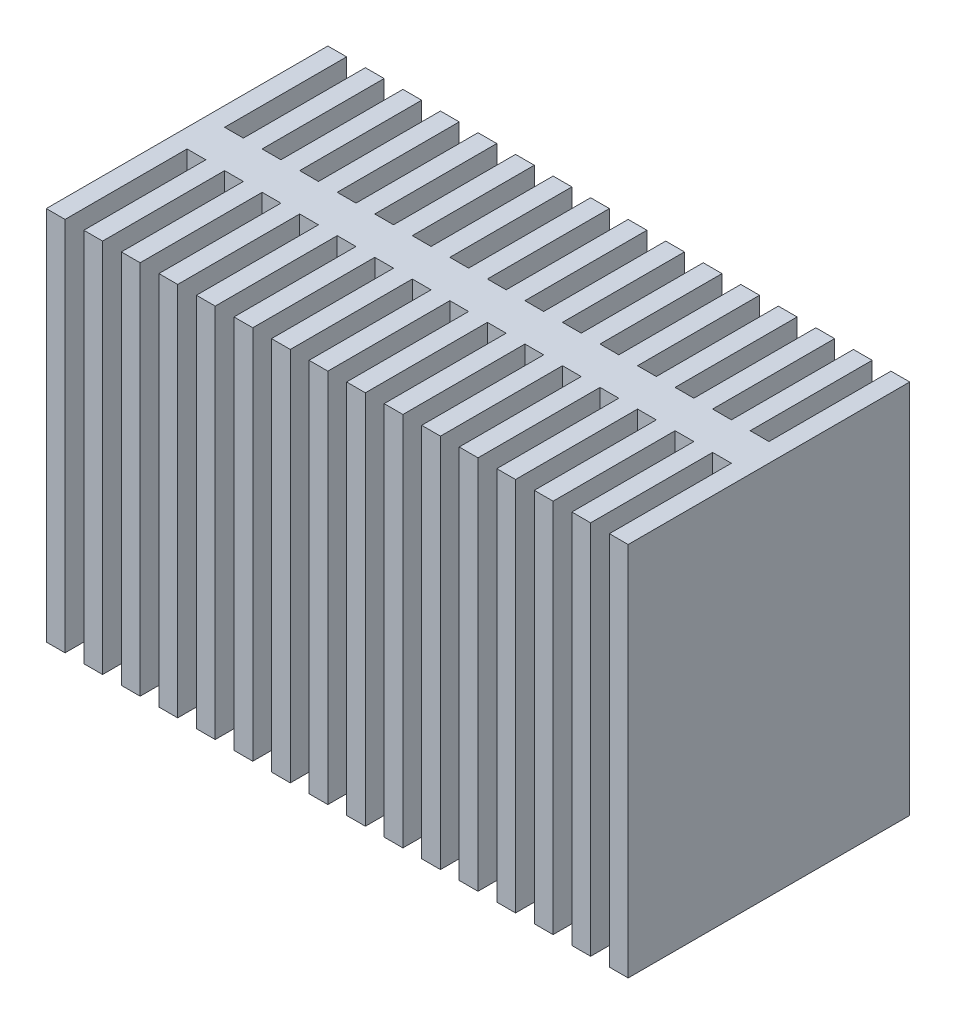
from build123d import *

# Parameters (mm, degrees)
SKETCH2_W           = 1
SKETCH2_H           = 2
BOSS_EXTRUDE1_DEPTH = 20


with BuildPart() as part:
    # Sketch2 → Boss-Extrude1 (new body)
    with BuildSketch(Plane(origin=(0, 0, 0), x_dir=(1, 0, 0), z_dir=(0, 1, 0))):
        Polygon((1, 0), (0, 0), (0, -15), (1, -15), (1, -8.5), (2, -8.5), (2, -6.5), (1, -6.5), align=None)
        Polygon((2, 0), (2, -6.5), (2, -8.5), (2, -15), (3, -15), (3, -8.5), (4, -8.5), (4, -6.5), (3, -6.5), (3, 0), align=None)
        Polygon((4, 0), (4, -6.5), (4, -8.5), (4, -15), (5, -15), (5, -8.5), (6, -8.5), (6, -6.5), (5, -6.5), (5, 0), align=None)
        Polygon((6, 0), (6, -6.5), (6, -8.5), (6, -15), (7, -15), (7, -8.5), (8, -8.5), (8, -6.5), (7, -6.5), (7, 0), align=None)
        Polygon((8, 0), (8, -6.5), (8, -8.5), (8, -15), (9, -15), (9, -8.5), (10, -8.5), (10, -6.5), (9, -6.5), (9, 0), align=None)
        Polygon((10, 0), (10, -6.5), (10, -8.5), (10, -15), (11, -15), (11, -8.5), (12, -8.5), (12, -6.5), (11, -6.5), (11, 0), align=None)
        Polygon((12, 0), (12, -6.5), (12, -8.5), (12, -15), (13, -15), (13, -8.5), (13, -6.5), (13, 0), align=None)
        with Locations((13.5, -7.5)):
            Rectangle(SKETCH2_W, SKETCH2_H)
        Polygon((14, 0), (14, -6.5), (14, -8.5), (14, -15), (15, -15), (15, -8.5), (16, -8.5), (16, -6.5), (15, -6.5), (15, 0), align=None)
        Polygon((16, 0), (16, -6.5), (16, -8.5), (16, -15), (17, -15), (17, -8.5), (18, -8.5), (18, -6.5), (17, -6.5), (17, 0), align=None)
        Polygon((18, 0), (18, -6.5), (18, -8.5), (18, -15), (19, -15), (19, -8.5), (20, -8.5), (20, -6.5), (19, -6.5), (19, 0), align=None)
        Polygon((20, 0), (20, -6.5), (20, -8.5), (20, -15), (21, -15), (21, -8.5), (22, -8.5), (22, -6.5), (21, -6.5), (21, 0), align=None)
        Polygon((22, 0), (22, -6.5), (22, -8.5), (22, -15), (23, -15), (23, -8.5), (24, -8.5), (24, -6.5), (23, -6.5), (23, 0), align=None)
        Polygon((24, 0), (24, -6.5), (24, -8.5), (24, -15), (25, -15), (25, -8.5), (26, -8.5), (26, -6.5), (25, -6.5), (25, 0), align=None)
        Polygon((26, 0), (26, -6.5), (26, -8.5), (26, -15), (27, -15), (27, -8.5), (28, -8.5), (28, -6.5), (27, -6.5), (27, 0), align=None)
        Polygon((28, 0), (28, -6.5), (28, -8.5), (28, -15), (29, -15), (29, -8.5), (30, -8.5), (30, -6.5), (29, -6.5), (29, 0), align=None)
        Polygon((30, 0), (30, -6.5), (30, -8.5), (30, -15), (31, -15), (31, 0), align=None)
    extrude(amount=BOSS_EXTRUDE1_DEPTH)


solid = part.part
